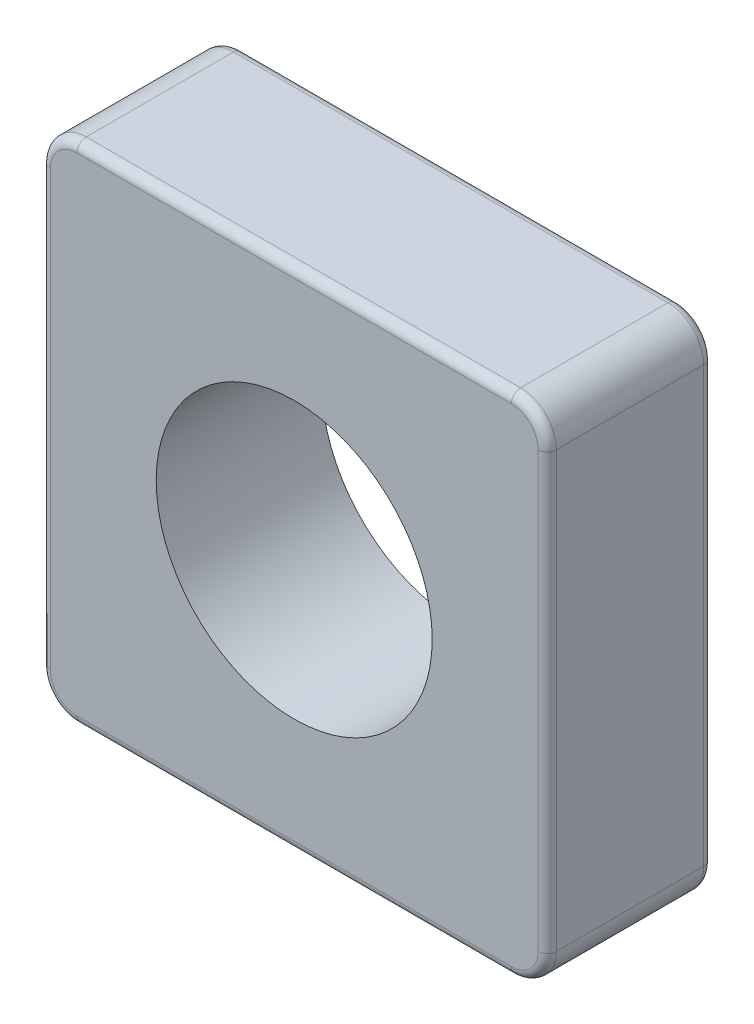
from build123d import *

# Parameters (mm, degrees)
SKETCH1_W           = 5.5
SKETCH1_H           = 5.5
SKETCH1_R           = 1.5
BOSS_EXTRUDE1_DEPTH = 1.8
FILLET1_R           = 0.389087297
FILLET2_R           = 0.1


with BuildPart() as part:
    # Sketch1 → Boss-Extrude1 (new body)
    with BuildSketch(Plane(origin=(0, 0, 0), x_dir=(0, 1, 0), z_dir=(0, 0, 1))):
        Rectangle(SKETCH1_W, SKETCH1_H)
        Circle(SKETCH1_R, mode=Mode.SUBTRACT)
    extrude(amount=BOSS_EXTRUDE1_DEPTH)

    # Fillet1
    fillet1_edges = [part.edges().sort_by_distance(p)[0] for p in [
        (2.75, 2.75, 0.9),
        (2.75, -2.75, 0.9),
        (-2.75, -2.75, 0.9),
        (-2.75, 2.75, 0.9),
    ]]
    fillet(fillet1_edges, radius=FILLET1_R)

    # Fillet2
    fillet2_edges = [part.edges().sort_by_distance(p)[0] for p in [
        (0, -2.75, 0),
        (0, -2.75, 1.8),
        (0, 2.75, 0),
        (2.75, 0, 0),
        (-2.75, 0, 0),
        (2.636038969, -2.636038969, 0),
        (2.636038969, 2.636038969, 0),
        (-2.636038969, 2.636038969, 0),
        (-2.636038969, -2.636038969, 0),
        (-2.75, 0, 1.8),
        (0, 2.75, 1.8),
        (2.75, 0, 1.8),
        (2.636038969, -2.636038969, 1.8),
        (2.636038969, 2.636038969, 1.8),
        (-2.636038969, 2.636038969, 1.8),
        (-2.636038969, -2.636038969, 1.8),
    ]]
    fillet(fillet2_edges, radius=FILLET2_R)


solid = part.part
